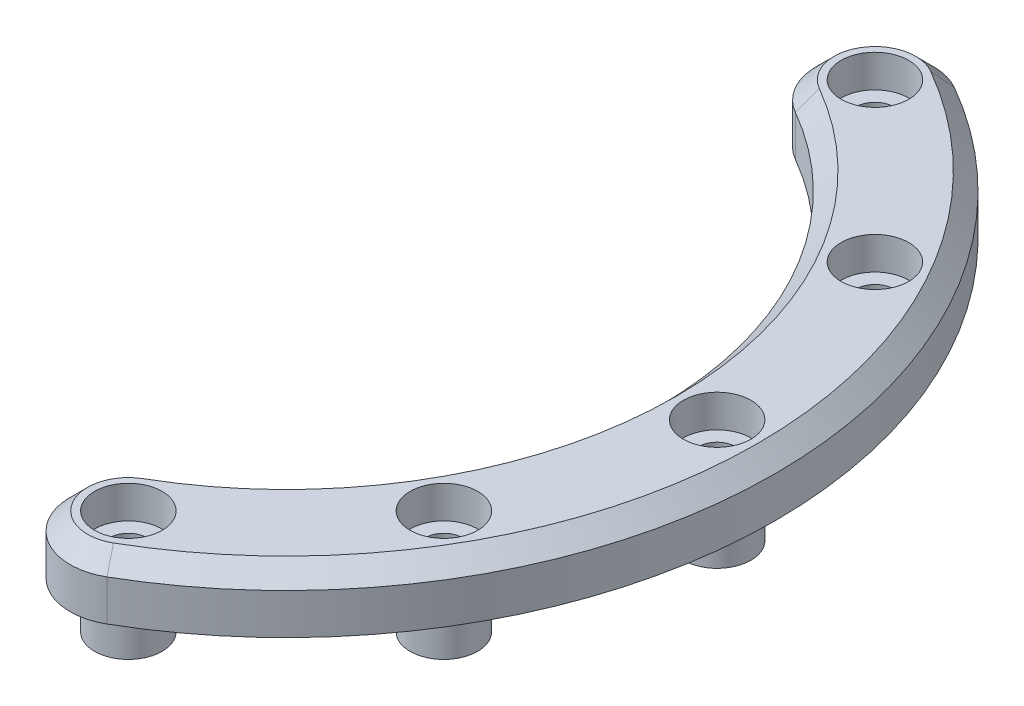
from build123d import *

# Parameters (mm, degrees)
EXTRUDE_1_DEPTH     = 5
SKETCH_3_R          = 2.9
EXTRUDE_3_DEPTH     = 4
SKETCH_4_R          = 1.6
CUT_EXTRUDE_1_DEPTH = 10
SKETCH_5_R          = 2.9
CUT_EXTRUDE_2_DEPTH = 2.8
CHAMFER_1_SIZE      = 1.5


with BuildPart() as part:
    # 草图1 → 凸台-拉伸1 (new body)
    with BuildSketch(Plane(origin=(0, 0, 0), x_dir=(1, 0, 0), z_dir=(0, 1, 0))):
        with BuildLine():
            ThreePointArc((21, -36.373066959), (14.169872981, -34.54293994), (16, -27.712812921))
            ThreePointArc((16, -27.712812921), (32, 0), (16, 27.712812921))
            ThreePointArc((16, 27.712812921), (14.169872981, 34.54293994), (21, 36.373066959))
            ThreePointArc((21, 36.373066959), (42, 0), (21, -36.373066959))
        make_face()
    extrude(amount=EXTRUDE_1_DEPTH)

    # 草图3 → 凸台-拉伸3 (add)
    with BuildSketch(Plane.XZ):
        with Locations((18.5, 32.04293994)):
            Circle(SKETCH_3_R)
        with Locations((32.04293994, 18.5)):
            Circle(SKETCH_3_R)
        with Locations((37, 0)):
            Circle(SKETCH_3_R)
        with Locations((32.04293994, -18.5)):
            Circle(SKETCH_3_R)
        with Locations((18.5, -32.04293994)):
            Circle(SKETCH_3_R)
    extrude(amount=EXTRUDE_3_DEPTH)

    # 草图4 → 切除-拉伸1 (cut, through all)
    with BuildSketch(Plane(origin=(0, 5, 0), x_dir=(1, 0, 0), z_dir=(0, 1, 0))):
        with Locations((18.5, 32.04293994)):
            Circle(SKETCH_4_R)
        with Locations((32.04293994, 18.5)):
            Circle(SKETCH_4_R)
        with Locations((37, 0)):
            Circle(SKETCH_4_R)
        with Locations((32.04293994, -18.5)):
            Circle(SKETCH_4_R)
        with Locations((18.5, -32.04293994)):
            Circle(SKETCH_4_R)
    extrude(amount=-CUT_EXTRUDE_1_DEPTH, mode=Mode.SUBTRACT)

    # 草图5 → 切除-拉伸2 (cut)
    with BuildSketch(Plane(origin=(0, 5, 0), x_dir=(1, 0, 0), z_dir=(0, 1, 0))):
        with Locations((18.5, 32.04293994)):
            Circle(SKETCH_5_R)
        with Locations((32.04293994, 18.5)):
            Circle(SKETCH_5_R)
        with Locations((37, 0)):
            Circle(SKETCH_5_R)
        with Locations((32.04293994, -18.5)):
            Circle(SKETCH_5_R)
        with Locations((18.5, -32.04293994)):
            Circle(SKETCH_5_R)
    extrude(amount=-CUT_EXTRUDE_2_DEPTH, mode=Mode.SUBTRACT)

    # 倒角1
    chamfer_1_edges = [part.edges().sort_by_distance(p)[0] for p in [
        (42, 5, 0),
        (14.169872981, 5, -34.54293994),
        (32, 5, 0),
        (14.169872981, 5, 34.54293994),
    ]]
    chamfer(chamfer_1_edges, length=CHAMFER_1_SIZE)


solid = part.part
